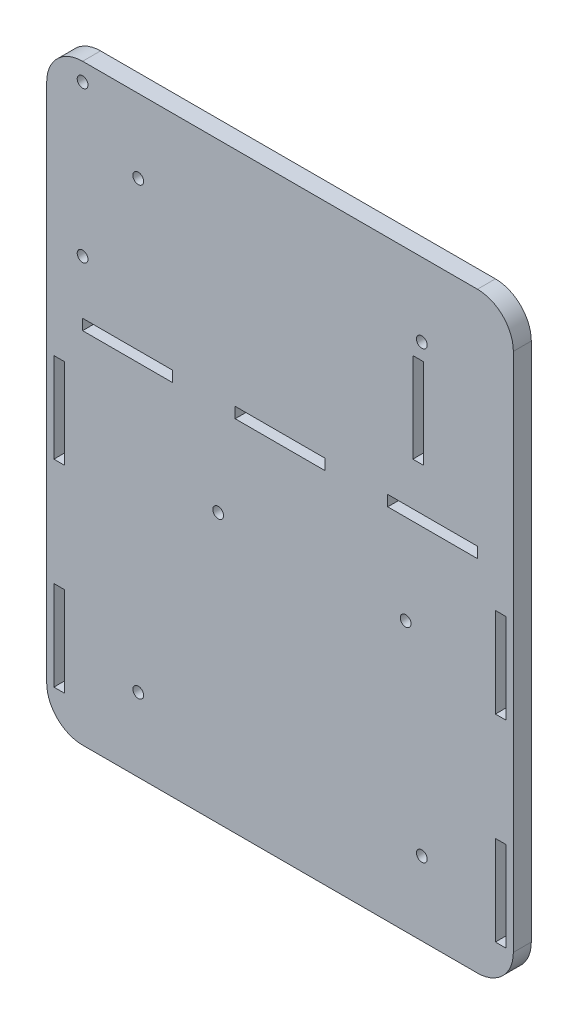
from build123d import *

# Parameters (mm, degrees)
RESSALTO_EXTRUS_O1_DEPTH = 5
ESBO_O2_R                = 1.5
CORTE_EXTRUS_O1_DEPTH    = 5
ESBO_O3_R                = 1.5
CORTE_EXTRUS_O2_DEPTH    = 6
ESBO_O6_W                = 3
ESBO_O6_H                = 25
ESBO_O6_W_2              = 25
ESBO_O6_H_2              = 3
CORTE_EXTRUS_O4_DEPTH    = 6
ESBO_O8_R                = 1.5
CORTE_EXTRUS_O6_DEPTH    = 10
ESBO_O9_W                = 3
ESBO_O9_H                = 25
CORTE_EXTRUS_O7_DEPTH    = 10


with BuildPart() as part:
    # Esboço1 → Ressalto-extrusão1 (new body)
    with BuildSketch(Plane.XY):
        with BuildLine():
            Line((-49.217119449, -36.393854661), (60.782880551, -36.393854661))
            ThreePointArc((60.782880551, -36.393854661), (67.853948363, -33.464922473), (70.782880551, -26.393854661))
            Line((70.782880551, -26.393854661), (70.782880551, 118.606145339))
            ThreePointArc((70.782880551, 118.606145339), (67.853948363, 125.67721315), (60.782880551, 128.606145339))
            Line((60.782880551, 128.606145339), (-49.217119449, 128.606145339))
            ThreePointArc((-49.217119449, 128.606145339), (-56.288187261, 125.67721315), (-59.217119449, 118.606145339))
            Line((-59.217119449, 118.606145339), (-59.217119449, -26.393854661))
            ThreePointArc((-59.217119449, -26.393854661), (-56.288187261, -33.464922473), (-49.217119449, -36.393854661))
        make_face()
    extrude(amount=RESSALTO_EXTRUS_O1_DEPTH)

    # Esboço2 → Corte-extrusão1 (cut)
    with BuildSketch(Plane(origin=(0, 0, 0), x_dir=(-1, 0, 0), z_dir=(0, 0, -1))):
        with Locations((33.717119449, -15.893854661)):
            Circle(ESBO_O2_R)
        with Locations((33.717119449, 108.106145339)):
            Circle(ESBO_O2_R)
        with Locations((-45.282880551, -15.893854661)):
            Circle(ESBO_O2_R)
        with Locations((-45.282880551, 108.106145339)):
            Circle(ESBO_O2_R)
    extrude(amount=-CORTE_EXTRUS_O1_DEPTH, mode=Mode.SUBTRACT)

    # Esboço3 → Corte-extrusão2 (cut, through all)
    with BuildSketch(Plane(origin=(0, 0, 0), x_dir=(-1, 0, 0), z_dir=(0, 0, -1))):
        with Locations((49.217119449, 123.606145339)):
            Circle(ESBO_O3_R)
        with Locations((49.217119449, 81.556145339)):
            Circle(ESBO_O3_R)
    extrude(amount=-CORTE_EXTRUS_O2_DEPTH, mode=Mode.SUBTRACT)

    # Esboço6 → Corte-extrusão4 (cut, through all)
    with BuildSketch(Plane(origin=(0, 0, 0), x_dir=(-1, 0, 0), z_dir=(0, 0, -1))):
        with Locations((-67.282880551, -13.893854661)):
            Rectangle(ESBO_O6_W, ESBO_O6_H)
        with Locations((-67.282880551, 41.106145339)):
            Rectangle(ESBO_O6_W, ESBO_O6_H)
        with Locations((-48.282880551, 65.106145339)):
            Rectangle(ESBO_O6_W_2, ESBO_O6_H_2)
        with Locations((36.717119449, 65.106145339)):
            Rectangle(ESBO_O6_W_2, ESBO_O6_H_2)
        with Locations((55.717119449, 41.106145339)):
            Rectangle(ESBO_O6_W, ESBO_O6_H)
        with Locations((55.717119449, -13.893854661)):
            Rectangle(ESBO_O6_W, ESBO_O6_H)
        with Locations((-5.782880551, 65.106145339)):
            Rectangle(ESBO_O6_W_2, ESBO_O6_H_2)
    extrude(amount=-CORTE_EXTRUS_O4_DEPTH, mode=Mode.SUBTRACT)

    # Esboço8 → Corte-extrusão6 (cut)
    with BuildSketch(Plane.XY.offset(5)):
        with Locations((-11.447119449, 38.606145339)):
            Circle(ESBO_O8_R)
        with Locations((40.782880551, 38.606145339)):
            Circle(ESBO_O8_R)
    extrude(amount=-CORTE_EXTRUS_O6_DEPTH, mode=Mode.SUBTRACT)

    # Esboço9 → Corte-extrusão7 (cut)
    with BuildSketch(Plane(origin=(0, 0, 0), x_dir=(-1, 0, 0), z_dir=(0, 0, -1))):
        with Locations((-44.282880551, 91.106145339)):
            Rectangle(ESBO_O9_W, ESBO_O9_H)
    extrude(amount=-CORTE_EXTRUS_O7_DEPTH, mode=Mode.SUBTRACT)


solid = part.part
